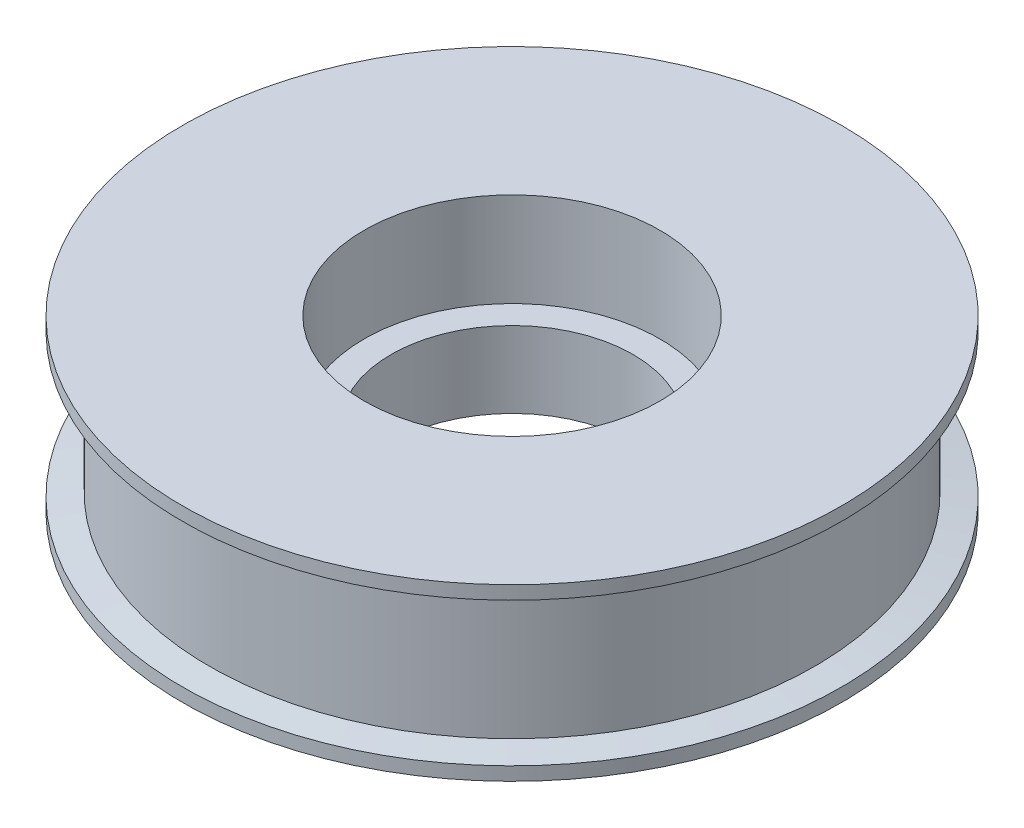
from build123d import *

# Parameters (mm, degrees)
SKETCH1_R           = 22.5
SKETCH1_R_2         = 11
BOSS_EXTRUDE1_DEPTH = 11.66


with BuildPart() as part:
    # Sketch1 → Boss-Extrude1 (new body)
    with BuildSketch(Plane(origin=(0, 0, 0), x_dir=(1, 0, 0), z_dir=(0, 1, 0))):
        Circle(SKETCH1_R)
        Circle(SKETCH1_R_2, mode=Mode.SUBTRACT)
    extrude(amount=BOSS_EXTRUDE1_DEPTH)

    # Sketch2 → Revolve1 (revolve)
    with BuildSketch(Plane.XY):
        Polygon((22.5, 11.66), (24.5, 11.66), (24.5, 10.66), (22.5, 10.33), align=None)
        Polygon((22.5, 0.33), (24.5, 0), (24.5, -1), (22.5, -1), (9, -1), (9, 0.33), (9, 4.66), (22.5, 4.66), align=None)
    revolve(axis=Axis((0, 0, 0), (0, 1, 0)))


solid = part.part
